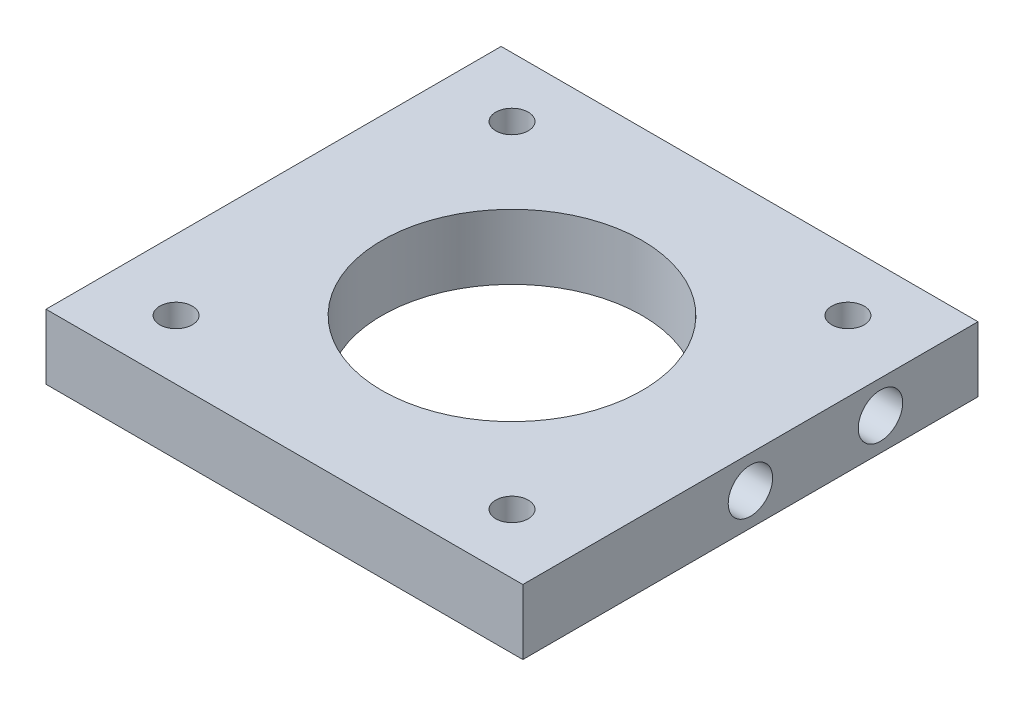
from build123d import *

# Parameters (mm, degrees)
SKETCH1_W           = 44
SKETCH1_H           = 6
BOSS_EXTRUDE1_DEPTH = 42
CUT_EXTRUDE4_REACH  = 8
SKETCH5_R           = 12
SKETCH5_R_2         = 1.5
SKETCH6_R           = 2.05
CUT_EXTRUDE5_DEPTH  = 6
SKETCH7_R           = 2.05
CUT_EXTRUDE6_DEPTH  = 6


with BuildPart() as part:
    # Sketch1 → Boss-Extrude1 (new body)
    with BuildSketch(Plane.XY):
        Rectangle(SKETCH1_W, SKETCH1_H)
    extrude(amount=BOSS_EXTRUDE1_DEPTH)

    # Sketch5 → Cut-Extrude4 (cut, up to next)
    with BuildSketch(Plane(origin=(0, 3, 0), x_dir=(1, 0, 0), z_dir=(0, 1, 0)), mode=Mode.PRIVATE) as cut_extrude4_sk1:
        with Locations((0, -21)):
            Circle(SKETCH5_R)
    cut_extrude4_tool1 = extrude(cut_extrude4_sk1.sketch, amount=-CUT_EXTRUDE4_REACH, mode=Mode.PRIVATE) & part.part
    add(cut_extrude4_tool1.solids().sort_by_distance((0, 3, 21))[0], mode=Mode.SUBTRACT)
    # Sketch5 → Cut-Extrude4 (cut, up to next)
    with BuildSketch(Plane(origin=(0, 3, 0), x_dir=(1, 0, 0), z_dir=(0, 1, 0)), mode=Mode.PRIVATE) as cut_extrude4_sk2:
        with Locations((-15.5, -5.5)):
            Circle(SKETCH5_R_2)
    cut_extrude4_tool2 = extrude(cut_extrude4_sk2.sketch, amount=-CUT_EXTRUDE4_REACH, mode=Mode.PRIVATE) & part.part
    add(cut_extrude4_tool2.solids().sort_by_distance((-15.5, 3, 5.5))[0], mode=Mode.SUBTRACT)
    # Sketch5 → Cut-Extrude4 (cut, up to next)
    with BuildSketch(Plane(origin=(0, 3, 0), x_dir=(1, 0, 0), z_dir=(0, 1, 0)), mode=Mode.PRIVATE) as cut_extrude4_sk3:
        with Locations((15.5, -5.5)):
            Circle(SKETCH5_R_2)
    cut_extrude4_tool3 = extrude(cut_extrude4_sk3.sketch, amount=-CUT_EXTRUDE4_REACH, mode=Mode.PRIVATE) & part.part
    add(cut_extrude4_tool3.solids().sort_by_distance((15.5, 3, 5.5))[0], mode=Mode.SUBTRACT)
    # Sketch5 → Cut-Extrude4 (cut, up to next)
    with BuildSketch(Plane(origin=(0, 3, 0), x_dir=(1, 0, 0), z_dir=(0, 1, 0)), mode=Mode.PRIVATE) as cut_extrude4_sk4:
        with Locations((15.5, -36.5)):
            Circle(SKETCH5_R_2)
    cut_extrude4_tool4 = extrude(cut_extrude4_sk4.sketch, amount=-CUT_EXTRUDE4_REACH, mode=Mode.PRIVATE) & part.part
    add(cut_extrude4_tool4.solids().sort_by_distance((15.5, 3, 36.5))[0], mode=Mode.SUBTRACT)
    # Sketch5 → Cut-Extrude4 (cut, up to next)
    with BuildSketch(Plane(origin=(0, 3, 0), x_dir=(1, 0, 0), z_dir=(0, 1, 0)), mode=Mode.PRIVATE) as cut_extrude4_sk5:
        with Locations((-15.5, -36.5)):
            Circle(SKETCH5_R_2)
    cut_extrude4_tool5 = extrude(cut_extrude4_sk5.sketch, amount=-CUT_EXTRUDE4_REACH, mode=Mode.PRIVATE) & part.part
    add(cut_extrude4_tool5.solids().sort_by_distance((-15.5, 3, 36.5))[0], mode=Mode.SUBTRACT)

    # Sketch6 → Cut-Extrude5 (cut)
    with BuildSketch(Plane.ZY.offset(22)):
        with Locations((9, 0)):
            Circle(SKETCH6_R)
        with Locations((21, 0)):
            Circle(SKETCH6_R)
    extrude(amount=-CUT_EXTRUDE5_DEPTH, mode=Mode.SUBTRACT)

    # Sketch7 → Cut-Extrude6 (cut)
    with BuildSketch(Plane(origin=(22, 0, 0), x_dir=(0, 0, -1), z_dir=(1, 0, 0))):
        with Locations((-9, 0)):
            Circle(SKETCH7_R)
        with Locations((-21, 0)):
            Circle(SKETCH7_R)
    extrude(amount=-CUT_EXTRUDE6_DEPTH, mode=Mode.SUBTRACT)


solid = part.part
